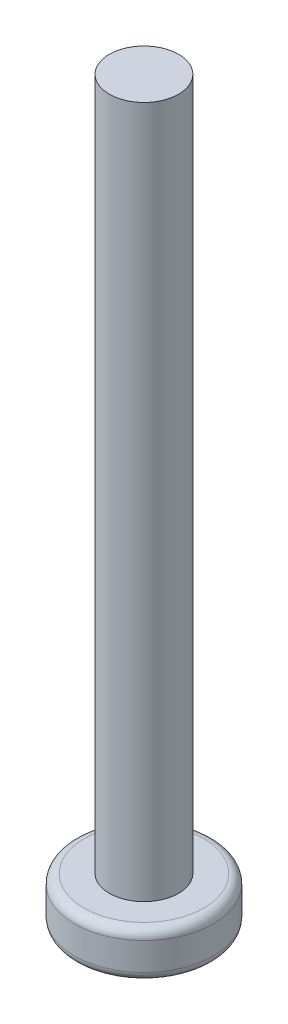
from build123d import *

# Parameters (mm, degrees)
SKETCH1_R           = 3
BOSS_EXTRUDE1_DEPTH = 2
SKETCH2_R           = 1.5
BOSS_EXTRUDE2_DEPTH = 30
SKETCH3_W           = 0.9
SKETCH3_H           = 0.9
SKETCH3_W_2         = 1.05
SKETCH3_H_2         = 1.05
CUT_EXTRUDE1_DEPTH  = 1.9
FILLET1_R           = 0.4


with BuildPart() as part:
    # Sketch1 → Boss-Extrude1 (new body)
    with BuildSketch(Plane(origin=(0, 0, 0), x_dir=(1, 0, 0), z_dir=(0, 1, 0))):
        Circle(SKETCH1_R)
    extrude(amount=BOSS_EXTRUDE1_DEPTH)

    # Sketch2 → Boss-Extrude2 (add)
    with BuildSketch(Plane(origin=(0, 2, 0), x_dir=(1, 0, 0), z_dir=(0, 1, 0))):
        Circle(SKETCH2_R)
    extrude(amount=BOSS_EXTRUDE2_DEPTH)

    # Sketch3 → Cut-Extrude1 (cut)
    with BuildSketch(Plane(origin=(0, 0, 0), x_dir=(-1, 0, 0), z_dir=(0, -1, 0))):
        Rectangle(SKETCH3_W, SKETCH3_H)
        with Locations((0.975, 0)):
            Rectangle(SKETCH3_W_2, SKETCH3_H)
        with Locations((0, -0.975)):
            Rectangle(SKETCH3_W, SKETCH3_H_2)
        with Locations((-0.975, 0)):
            Rectangle(SKETCH3_W_2, SKETCH3_H)
        with Locations((0, 0.975)):
            Rectangle(SKETCH3_W, SKETCH3_H_2)
    extrude(amount=-CUT_EXTRUDE1_DEPTH, mode=Mode.SUBTRACT)

    # Fillet1
    fillet1_edges = [part.edges().sort_by_distance(p)[0] for p in [
        (-3, 0, 0),
        (-3, 2, 0),
    ]]
    fillet(fillet1_edges, radius=FILLET1_R)


solid = part.part
